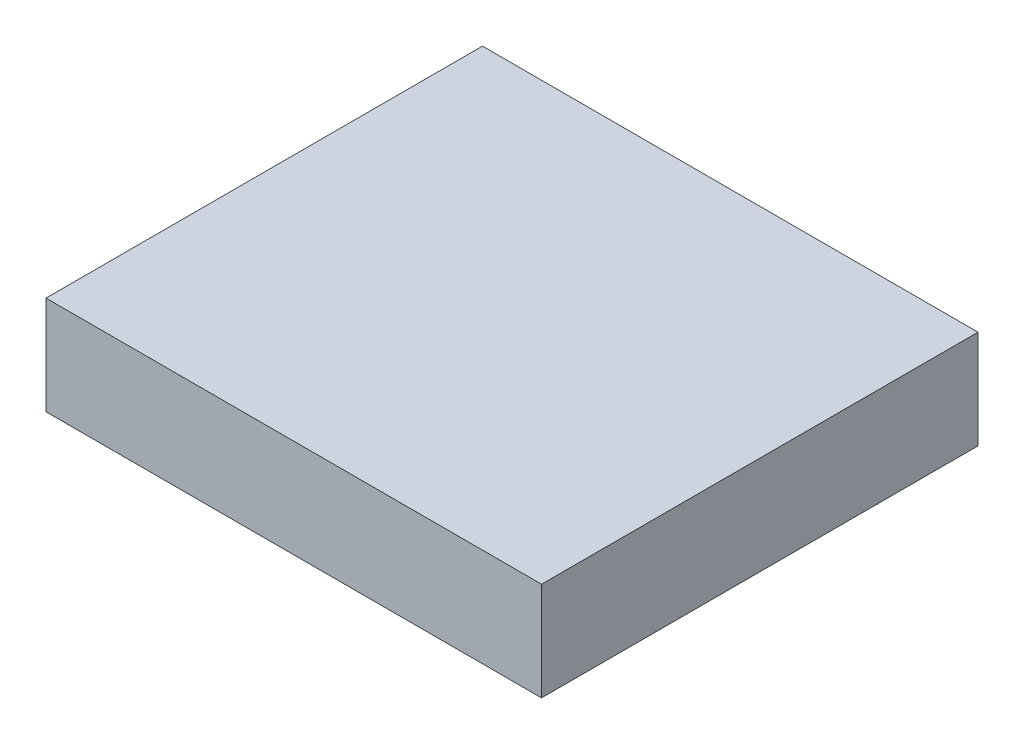
from build123d import *

# Parameters (mm, degrees)
SKETCH1_W           = 15.1
SKETCH1_H           = 13.3
BOSS_EXTRUDE1_DEPTH = 3


with BuildPart() as part:
    # Sketch1 → Boss-Extrude1 (new body)
    with BuildSketch(Plane(origin=(0, 0, 0), x_dir=(1, 0, 0), z_dir=(0, 1, 0))):
        with Locations((7.55, -6.65)):
            Rectangle(SKETCH1_W, SKETCH1_H)
    extrude(amount=BOSS_EXTRUDE1_DEPTH)


solid = part.part
